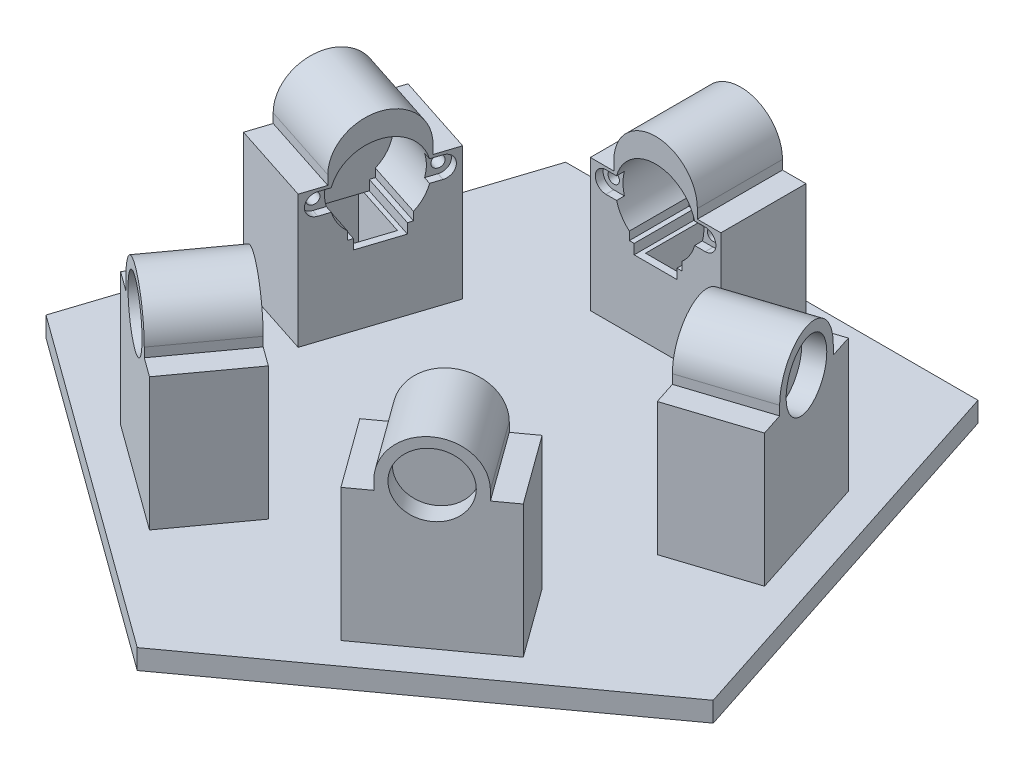
from build123d import *

# Parameters (mm, degrees)
BASE_DEPTH          = 7
BOSS_EXTRUDE1_DEPTH = 20.95
BOSS_EXTRUDE2_DEPTH = 9.05
SKETCH6_R           = 2
CUT_EXTRUDE2_DEPTH  = 10
CUT_EXTRUDE3_DEPTH  = 2.75
SKETCH8_W           = 8.290514233
SKETCH8_H           = 3.25
CUT_EXTRUDE4_DEPTH  = 227.650575612
SKETCH11_R          = 11.15
BEARING_HOLE_DEPTH  = 7
SKETCH9_W           = 12.1
SKETCH9_H           = 21.5
WIRE_HOLE_DEPTH     = 20
CIRPATTERN2_COUNT   = 5
SKETCH13_R          = 5
CAMERA_HOLE_DEPTH   = 183.443465519


with BuildPart() as part:
    # Sketch12 → Base (new body)
    with BuildSketch(Plane(origin=(0, 0, 0), x_dir=(1, 0, 0), z_dir=(0, 1, 0))):
        Polygon((0, -123.60679775), (117.557050458, -38.196601125), (72.654252801, 100), (-72.654252801, 100), (-117.557050458, -38.196601125), align=None)
    extrude(amount=-BASE_DEPTH)

    # Sketch13 → Camera Hole (cut, through all)
    with BuildSketch(Plane(origin=(0, 0, 0), x_dir=(1, 0, 0), z_dir=(0, 1, 0))):
        Circle(SKETCH13_R)
    extrude(amount=-CAMERA_HOLE_DEPTH, mode=Mode.SUBTRACT)


with BuildPart() as body_2:
    # Sketch2 → Boss-Extrude1 (new body)
    with BuildSketch(Plane.XY.offset(-80)):
        with BuildLine():
            Line((-14.709485767, 50), (-23, 50))
            Line((-23, 50), (-23, 0))
            Line((-23, 0), (23, 0))
            Line((23, 0), (23, 50))
            Line((23, 50), (14.709485767, 50))
            ThreePointArc((14.709485767, 50), (0, 64.709485767), (-14.709485767, 50))
        make_face()
        with BuildLine():
            Line((-7.55, 28.241114036), (-7.55, 24.75))
            Line((-7.55, 24.75), (7.55, 24.75))
            Line((7.55, 24.75), (7.55, 28.241114036))
            Line((7.55, 28.241114036), (9.25, 28.241114036))
            Line((9.25, 28.241114036), (9.25, 31.160258306))
            ThreePointArc((9.25, 31.160258306), (0, 56.25), (-9.25, 31.160258306))
            Line((-9.25, 31.160258306), (-9.25, 28.241114036))
            Line((-9.25, 28.241114036), (-7.55, 28.241114036))
        make_face(mode=Mode.SUBTRACT)
    extrude(amount=BOSS_EXTRUDE1_DEPTH)

    # Sketch3 → Boss-Extrude2 (add)
    with BuildSketch(Plane.XY.offset(-80)):
        with BuildLine():
            Line((-14.709485767, 50), (-23, 50))
            Line((-23, 50), (-23, 0))
            Line((-23, 0), (23, 0))
            Line((23, 0), (23, 50))
            Line((23, 50), (14.709485767, 50))
            ThreePointArc((14.709485767, 50), (0, 64.709485767), (-14.709485767, 50))
        make_face()
    extrude(amount=-BOSS_EXTRUDE2_DEPTH)

    # Sketch6 → Cut-Extrude2 (cut)
    with BuildSketch(Plane.XY.offset(-59.05)):
        with Locations((-17.5, 42)):
            Circle(SKETCH6_R)
        with Locations((17.5, 42)):
            Circle(SKETCH6_R)
    extrude(amount=-CUT_EXTRUDE2_DEPTH, mode=Mode.SUBTRACT)

    # Sketch7 → Cut-Extrude3 (cut)
    with BuildSketch(Plane.XY.offset(-59.05)):
        with BuildLine():
            Line((-17.5, 45.75), (17.5, 45.75))
            ThreePointArc((17.5, 45.75), (21.25, 42), (17.5, 38.25))
            Line((17.5, 38.25), (-17.5, 38.25))
            ThreePointArc((-17.5, 38.25), (-21.25, 42), (-17.5, 45.75))
        make_face()
    extrude(amount=-CUT_EXTRUDE3_DEPTH, mode=Mode.SUBTRACT)

    # Sketch8 → Cut-Extrude4 (cut, symmetric)
    with BuildSketch(Plane.XY.offset(-59.05)):
        with Locations((-18.854742884, 48.375)):
            Rectangle(SKETCH8_W, SKETCH8_H)
        with Locations((18.854742884, 48.375)):
            Rectangle(SKETCH8_W, SKETCH8_H)
    extrude(amount=CUT_EXTRUDE4_DEPTH, both=True, mode=Mode.SUBTRACT)

    # Sketch11 → Bearing Hole (cut)
    with BuildSketch(Plane(origin=(0, 0, -89.05), x_dir=(-1, 0, 0), z_dir=(0, 0, -1))):
        with Locations((0, 50)):
            Circle(SKETCH11_R)
    extrude(amount=-BEARING_HOLE_DEPTH, mode=Mode.SUBTRACT)

    # Sketch9 → Wire Hole (cut)
    with BuildSketch(Plane(origin=(0, 24.75, -19.25), x_dir=(-1, 0, 0), z_dir=(0, 1, 0))):
        with Locations((0, -53.05)):
            Rectangle(SKETCH9_W, SKETCH9_H)
    extrude(amount=-WIRE_HOLE_DEPTH, mode=Mode.SUBTRACT)


with BuildPart() as cirpattern2_1:
    # CirPattern2: pattern copy
    add(body_2.part.rotate(Axis((0, -9.447974288, 0), (0, 1, 0)), 1 * 360 / CIRPATTERN2_COUNT))


with BuildPart() as cirpattern2_2:
    # CirPattern2: pattern copy
    add(body_2.part.rotate(Axis((0, -9.447974288, 0), (0, 1, 0)), 2 * 360 / CIRPATTERN2_COUNT))


with BuildPart() as cirpattern2_3:
    # CirPattern2: pattern copy
    add(body_2.part.rotate(Axis((0, -9.447974288, 0), (0, 1, 0)), 3 * 360 / CIRPATTERN2_COUNT))


with BuildPart() as cirpattern2_4:
    # CirPattern2: pattern copy
    add(body_2.part.rotate(Axis((0, -9.447974288, 0), (0, 1, 0)), 4 * 360 / CIRPATTERN2_COUNT))


solid = Compound([part.part, body_2.part, cirpattern2_1.part, cirpattern2_2.part, cirpattern2_3.part, cirpattern2_4.part])
